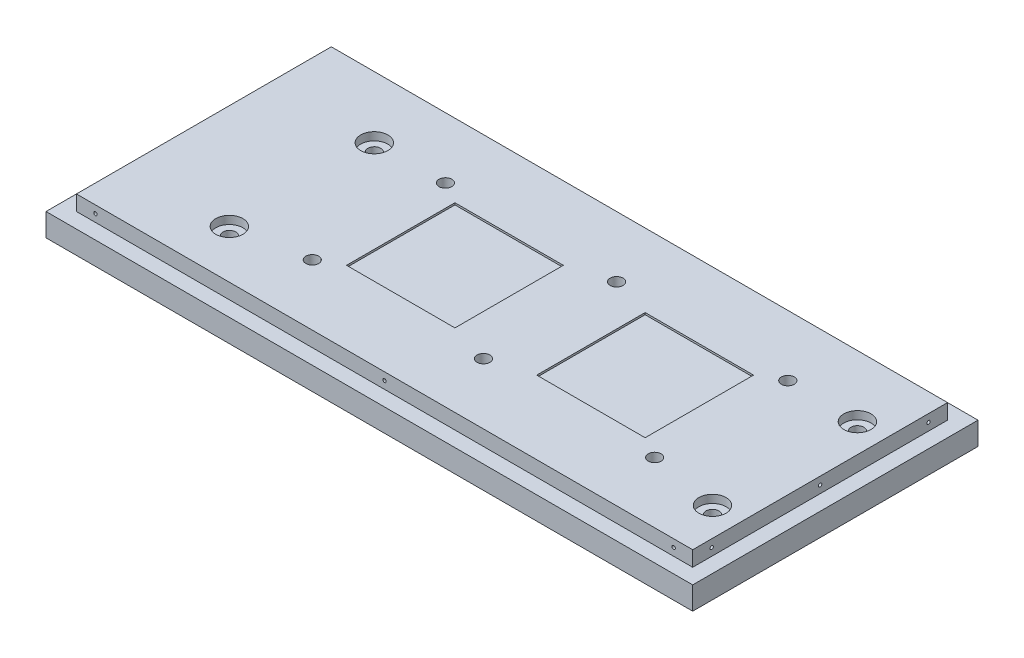
from build123d import *

# Parameters (mm, degrees)
SKETCH1_W                                            = 340
SKETCH1_H                                            = 150
BOSS_EXTRUDE1_DEPTH                                  = 20
LASERCAVITYMOUNTINGHOLE_CBORE_FOR_1_4_SO_D           = 6.7564
LASERCAVITYMOUNTINGHOLE_CBORE_FOR_1_4_SO_CBORE_D     = 11.1125
LASERCAVITYMOUNTINGHOLE_CBORE_FOR_1_4_SO_CBORE_DEPTH = 6.35
SKETCH5_W                                            = 57
SKETCH5_H                                            = 57
TEC_GROOVE_DEPTH                                     = 1
SKETCH6_W                                            = 340
SKETCH6_H                                            = 8
WALL1_DEPTH                                          = 8
SKETCH7_W                                            = 142
SKETCH7_H                                            = 8
WALL2_DEPTH                                          = 8
SKETCH9_W                                            = 332
SKETCH9_H                                            = 8
WALL3_DEPTH                                          = 8
SKETCH10_W                                           = 134
SKETCH10_H                                           = 8
WALL4_DEPTH                                          = 8
F_2_56_TAPPED_HOLE1_D                                = 1.778
F_2_56_TAPPED_HOLE1_DEPTH                            = 15
F_2_56_TAPPED_HOLE1_TIP                              = 0.53416509
F_2_56_TAPPED_HOLE2_D                                = 1.778
F_2_56_TAPPED_HOLE2_DEPTH                            = 15
F_2_56_TAPPED_HOLE2_TIP                              = 0.53416509
F_2_56_TAPPED_HOLE3_D                                = 1.778
F_2_56_TAPPED_HOLE3_DEPTH                            = 15
F_2_56_TAPPED_HOLE3_TIP                              = 0.53416509
F_2_56_TAPPED_HOLE4_D                                = 1.778
F_2_56_TAPPED_HOLE4_DEPTH                            = 15
F_2_56_TAPPED_HOLE4_TIP                              = 0.53416509
OPTICALTABLEMOUNTINGHOLES_CBORE_FOR_1_4_D            = 6.7564
OPTICALTABLEMOUNTINGHOLES_CBORE_FOR_1_4_DEPTH        = 20
OPTICALTABLEMOUNTINGHOLES_CBORE_FOR_1_4_CBORE_D      = 14.2875
OPTICALTABLEMOUNTINGHOLES_CBORE_FOR_1_4_CBORE_DEPTH  = 4.191
OPTICALTABLEMOUNTINGHOLES_CBORE_FOR_1_4_TIP          = 2.029827343


with BuildPart() as part:
    # Sketch1 → Boss-Extrude1 (new body)
    with BuildSketch(Plane(origin=(0, 0, 0), x_dir=(1, 0, 0), z_dir=(0, 1, 0))):
        with Locations((170, 75)):
            Rectangle(SKETCH1_W, SKETCH1_H)
    extrude(amount=BOSS_EXTRUDE1_DEPTH)

    # LaserCavityMountingHole_CBORE for 1/4 Socket Head Cap Screw1 (through all)
    with Locations(Plane(origin=(0, 0, 0), x_dir=(-1, 0, 0), z_dir=(0, -1, 0))):
        with Locations((-100, 40), (-190, 40), (-280, 40), (-280, 110), (-190, 110), (-100, 110)):
            CounterBoreHole(LASERCAVITYMOUNTINGHOLE_CBORE_FOR_1_4_SO_D / 2, LASERCAVITYMOUNTINGHOLE_CBORE_FOR_1_4_SO_CBORE_D / 2, LASERCAVITYMOUNTINGHOLE_CBORE_FOR_1_4_SO_CBORE_DEPTH)

    # Sketch5 → TEC_groove (cut)
    with BuildSketch(Plane(origin=(0, 20, 0), x_dir=(1, 0, 0), z_dir=(0, 1, 0))):
        with Locations((140, 75)):
            Rectangle(SKETCH5_W, SKETCH5_H)
        with Locations((240, 75)):
            Rectangle(SKETCH5_W, SKETCH5_H)
    extrude(amount=-TEC_GROOVE_DEPTH, mode=Mode.SUBTRACT)

    # Sketch6 → Wall1 (cut)
    with BuildSketch(Plane.XY):
        with Locations((170, 16)):
            Rectangle(SKETCH6_W, SKETCH6_H)
    extrude(amount=-WALL1_DEPTH, mode=Mode.SUBTRACT)

    # Sketch7 → Wall2 (cut)
    with BuildSketch(Plane(origin=(340, 0, 0), x_dir=(0, 0, -1), z_dir=(1, 0, 0))):
        with Locations((79, 16)):
            Rectangle(SKETCH7_W, SKETCH7_H)
    extrude(amount=-WALL2_DEPTH, mode=Mode.SUBTRACT)

    # Sketch9 → Wall3 (cut)
    with BuildSketch(Plane(origin=(0, 0, -150), x_dir=(-1, 0, 0), z_dir=(0, 0, -1))):
        with Locations((-166, 16)):
            Rectangle(SKETCH9_W, SKETCH9_H)
    extrude(amount=-WALL3_DEPTH, mode=Mode.SUBTRACT)

    # Sketch10 → Wall4 (cut)
    with BuildSketch(Plane.ZY):
        with Locations((-75, 16)):
            Rectangle(SKETCH10_W, SKETCH10_H)
    extrude(amount=-WALL4_DEPTH, mode=Mode.SUBTRACT)

    # #2-56 Tapped Hole1
    with Locations(Plane.XY.offset(-8)):
        with Locations((18, 16), (322, 16), (170, 16)):
            Hole(F_2_56_TAPPED_HOLE1_D / 2, depth=F_2_56_TAPPED_HOLE1_DEPTH)
            with Locations((0, 0, -(F_2_56_TAPPED_HOLE1_DEPTH + F_2_56_TAPPED_HOLE1_TIP / 2))):  # 118° drill point
                Cone(0, F_2_56_TAPPED_HOLE1_D / 2, F_2_56_TAPPED_HOLE1_TIP, mode=Mode.SUBTRACT)

    # #2-56 Tapped Hole2
    with Locations(Plane(origin=(8, 16, -132), x_dir=(0, 0, -1), z_dir=(-1, 0, 0))):
        with Locations((0, 0), (-114, 0), (-57, 0)):
            Hole(F_2_56_TAPPED_HOLE2_D / 2, depth=F_2_56_TAPPED_HOLE2_DEPTH)
            with Locations((0, 0, -(F_2_56_TAPPED_HOLE2_DEPTH + F_2_56_TAPPED_HOLE2_TIP / 2))):  # 118° drill point
                Cone(0, F_2_56_TAPPED_HOLE2_D / 2, F_2_56_TAPPED_HOLE2_TIP, mode=Mode.SUBTRACT)

    # #2-56 Tapped Hole3
    with Locations(Plane(origin=(0, 0, -142), x_dir=(-1, 0, 0), z_dir=(0, 0, -1))):
        with Locations((-322, 16), (-18, 16), (-170, 16)):
            Hole(F_2_56_TAPPED_HOLE3_D / 2, depth=F_2_56_TAPPED_HOLE3_DEPTH)
            with Locations((0, 0, -(F_2_56_TAPPED_HOLE3_DEPTH + F_2_56_TAPPED_HOLE3_TIP / 2))):  # 118° drill point
                Cone(0, F_2_56_TAPPED_HOLE3_D / 2, F_2_56_TAPPED_HOLE3_TIP, mode=Mode.SUBTRACT)

    # #2-56 Tapped Hole4
    with Locations(Plane(origin=(332, 0, 0), x_dir=(0, 0, -1), z_dir=(1, 0, 0))):
        with Locations((18, 16), (132, 16), (75, 16)):
            Hole(F_2_56_TAPPED_HOLE4_D / 2, depth=F_2_56_TAPPED_HOLE4_DEPTH)
            with Locations((0, 0, -(F_2_56_TAPPED_HOLE4_DEPTH + F_2_56_TAPPED_HOLE4_TIP / 2))):  # 118° drill point
                Cone(0, F_2_56_TAPPED_HOLE4_D / 2, F_2_56_TAPPED_HOLE4_TIP, mode=Mode.SUBTRACT)

    # OpticalTableMountingHoles_CBORE for 1/4 Binding Head Machine Screw1
    with Locations(Plane(origin=(0, 20, 0), x_dir=(1, 0, 0), z_dir=(0, 1, 0))):
        with Locations((63, 109.6), (317, 109.6), (317, 33.4), (63, 33.4)):
            CounterBoreHole(OPTICALTABLEMOUNTINGHOLES_CBORE_FOR_1_4_D / 2, OPTICALTABLEMOUNTINGHOLES_CBORE_FOR_1_4_CBORE_D / 2, OPTICALTABLEMOUNTINGHOLES_CBORE_FOR_1_4_CBORE_DEPTH, depth=OPTICALTABLEMOUNTINGHOLES_CBORE_FOR_1_4_DEPTH)
            with Locations((0, 0, -(OPTICALTABLEMOUNTINGHOLES_CBORE_FOR_1_4_DEPTH + OPTICALTABLEMOUNTINGHOLES_CBORE_FOR_1_4_TIP / 2))):  # 118° drill point
                Cone(0, OPTICALTABLEMOUNTINGHOLES_CBORE_FOR_1_4_D / 2, OPTICALTABLEMOUNTINGHOLES_CBORE_FOR_1_4_TIP, mode=Mode.SUBTRACT)


solid = part.part
